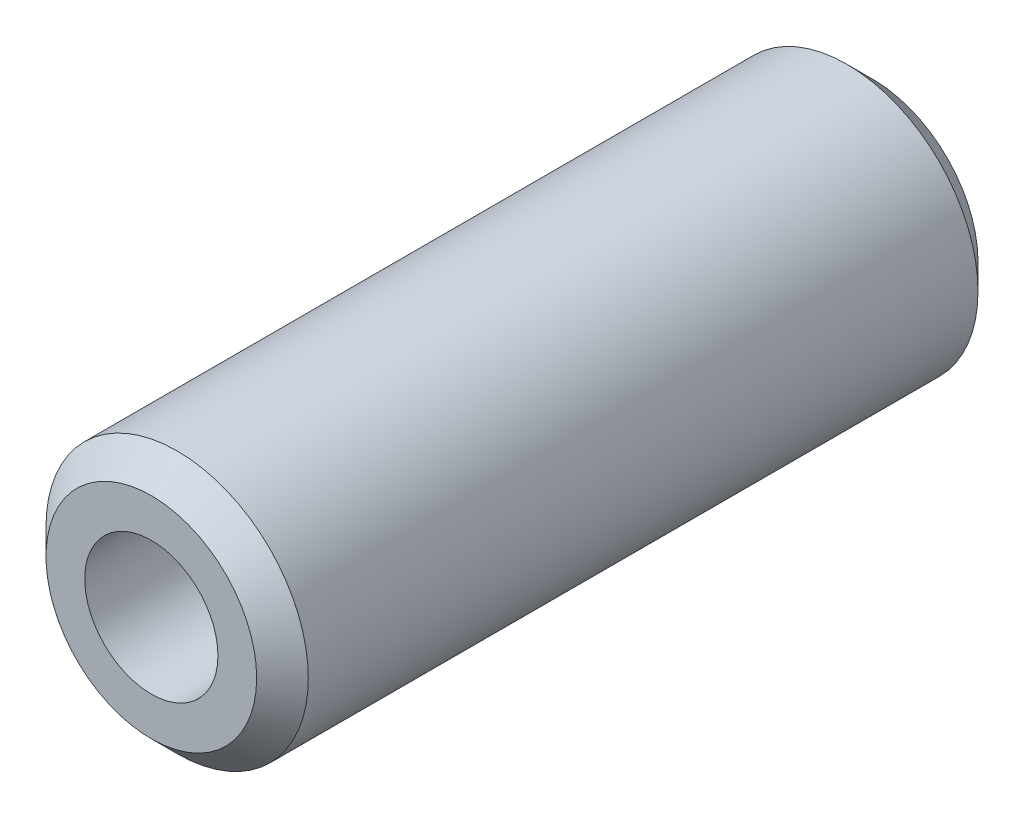
from build123d import *

# Parameters (mm, degrees)
SKETCH2_R               = 12.7
BOSS_EXTRUDE1_DEPTH     = 69.85
SKETCH3_R               = 6.45
CUT_EXTRUDE1_DEPTH      = 1
CUT_EXTRUDE1_DEPTH_BACK = 70.85
CHAMFER1_SIZE           = 2.5


with BuildPart() as part:
    # Sketch2 → Boss-Extrude1 (new body)
    with BuildSketch(Plane.XY):
        Circle(SKETCH2_R)
    extrude(amount=BOSS_EXTRUDE1_DEPTH)

    # Sketch3 → Cut-Extrude1 (cut, two sides)
    with BuildSketch(Plane.XY.offset(69.85)) as cut_extrude1_sk:
        Circle(SKETCH3_R)
    extrude(amount=CUT_EXTRUDE1_DEPTH, mode=Mode.SUBTRACT)
    extrude(cut_extrude1_sk.sketch, amount=-CUT_EXTRUDE1_DEPTH_BACK, mode=Mode.SUBTRACT)

    # Chamfer1
    chamfer1_edges = [part.edges().sort_by_distance(p)[0] for p in [
        (-12.7, 0, 0),
        (-12.7, 0, 69.85),
    ]]
    chamfer(chamfer1_edges, length=CHAMFER1_SIZE)


solid = part.part
